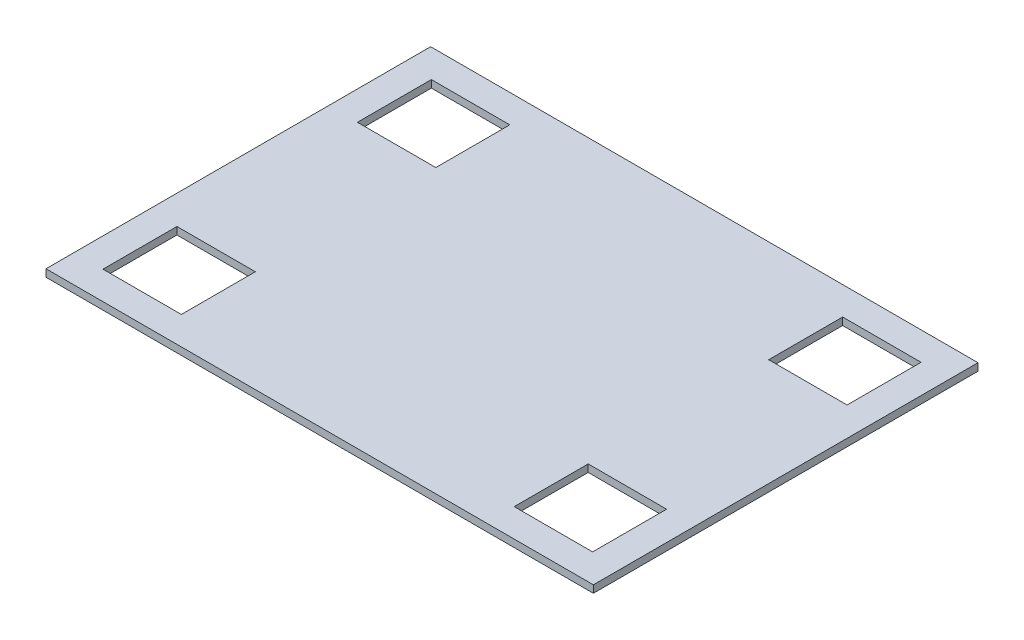
from build123d import *

# Parameters (mm, degrees)
SKETCH1_W           = 370
SKETCH1_H           = 260
BOSS_EXTRUDE1_DEPTH = 5
SKETCH3_W           = 53
SKETCH3_H           = 50
CUT_EXTRUDE3_DEPTH  = 10


with BuildPart() as part:
    # Sketch1 → Boss-Extrude1 (new body)
    with BuildSketch(Plane(origin=(0, 0, 0), x_dir=(1, 0, 0), z_dir=(0, 1, 0))):
        Rectangle(SKETCH1_W, SKETCH1_H)
    extrude(amount=BOSS_EXTRUDE1_DEPTH)

    # Sketch3 → Cut-Extrude3 (cut)
    with BuildSketch(Plane.XZ):
        with Locations((-139, 86)):
            Rectangle(SKETCH3_W, SKETCH3_H)
        with Locations((-139, -86)):
            Rectangle(SKETCH3_W, SKETCH3_H)
        with Locations((139, 86)):
            Rectangle(SKETCH3_W, SKETCH3_H)
        with Locations((139, -86)):
            Rectangle(SKETCH3_W, SKETCH3_H)
    extrude(amount=-CUT_EXTRUDE3_DEPTH, mode=Mode.SUBTRACT)


solid = part.part
